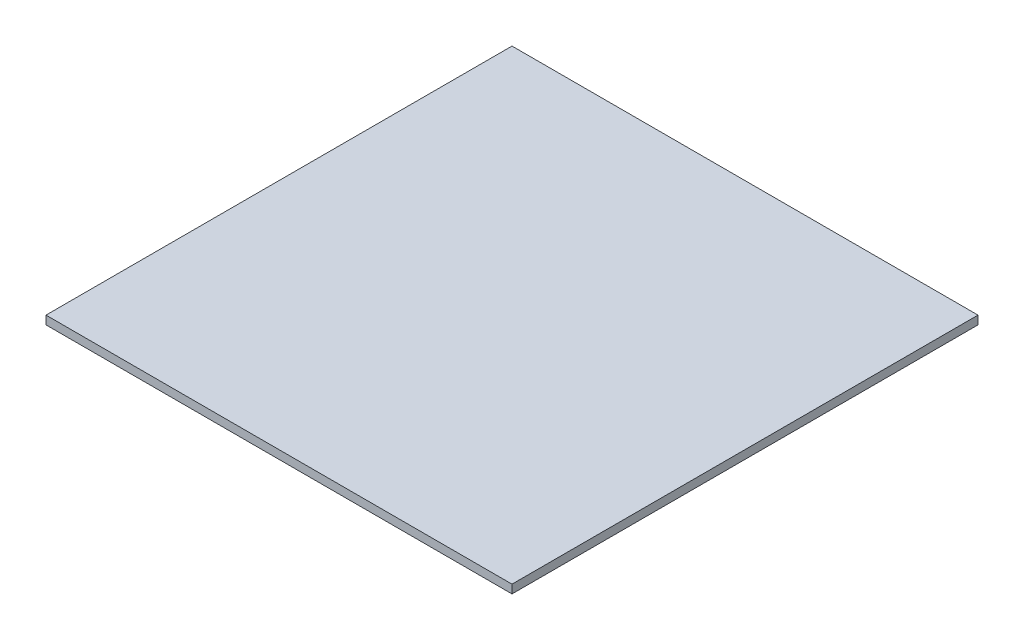
from build123d import *

# Parameters (mm, degrees)
SKETCH1_W           = 609.6
SKETCH1_H           = 609.6
BOSS_EXTRUDE1_DEPTH = 11.1125


with BuildPart() as part:
    # Sketch1 → Boss-Extrude1 (new body)
    with BuildSketch(Plane(origin=(0, 0, 0), x_dir=(1, 0, 0), z_dir=(0, 1, 0))):
        Rectangle(SKETCH1_W, SKETCH1_H)
    extrude(amount=BOSS_EXTRUDE1_DEPTH)


solid = part.part
